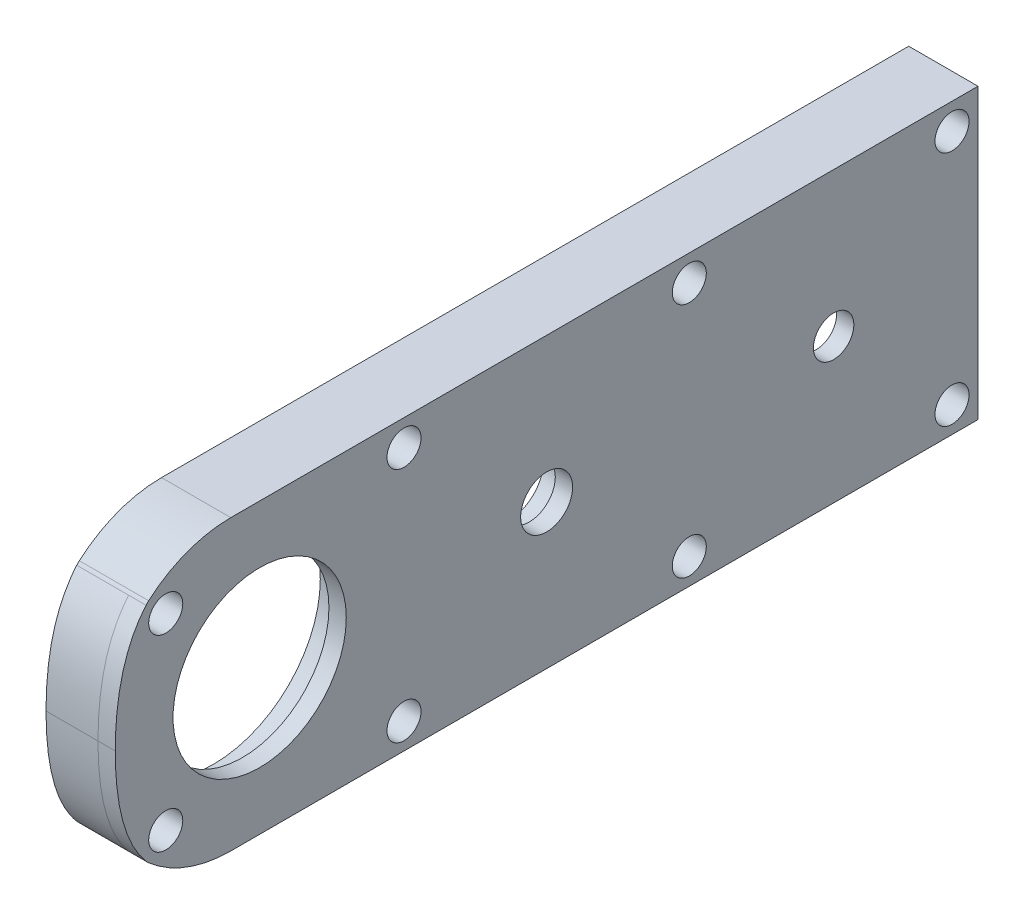
from build123d import *

# Parameters (mm, degrees)
SKETCH1_R           = 23
SKETCH1_R_2         = 18.5
BOSS_EXTRUDE1_DEPTH = 5
SKETCH2_R           = 9.5
SKETCH2_R_2         = 6
BOSS_EXTRUDE2_DEPTH = 3.5
SKETCH3_W           = 149.4
SKETCH3_H           = 50
SKETCH3_R           = 15
SKETCH3_R_2         = 4.5
SKETCH3_R_3         = 3.5
BOSS_EXTRUDE3_DEPTH = 3
BOSS_EXTRUDE4_DEPTH = 9
CUT_EXTRUDE1_DEPTH  = 128.205974827
SKETCH6_R           = 2
CUT_EXTRUDE2_DEPTH  = 128.453364147
SKETCH7_R           = 2.95
CUT_EXTRUDE3_DEPTH  = 5


with BuildPart() as part:
    # Sketch1 → Boss-Extrude1 (new body)
    with BuildSketch(Plane(origin=(0, 0, 0), x_dir=(0, 0, -1), z_dir=(1, 0, 0))):
        Circle(SKETCH1_R)
        Circle(SKETCH1_R_2, mode=Mode.SUBTRACT)
    extrude(amount=-BOSS_EXTRUDE1_DEPTH)



with BuildPart() as body_2:
    # Sketch2 → Boss-Extrude2 (new body)
    with BuildSketch(Plane(origin=(0, 0, 0), x_dir=(0, 0, -1), z_dir=(1, 0, 0))):
        with Locations((49.7, 0)):
            Circle(SKETCH2_R)
        with Locations((49.7, 0)):
            Circle(SKETCH2_R_2, mode=Mode.SUBTRACT)
    extrude(amount=-BOSS_EXTRUDE2_DEPTH)


with BuildPart() as part_1:
    add(part.part)

    add(body_2.part)  # Boss-Extrude3 merges body 2
    # Sketch3 → Boss-Extrude3 (add)
    with BuildSketch(Plane(origin=(0, 0, 0), x_dir=(0, 0, -1), z_dir=(1, 0, 0))):
        with Locations((49.7, 0)):
            Rectangle(SKETCH3_W, SKETCH3_H)
        Circle(SKETCH3_R, mode=Mode.SUBTRACT)
        with Locations((49.7, 0)):
            Circle(SKETCH3_R_2, mode=Mode.SUBTRACT)
        with Locations((99.4, 0)):
            Circle(SKETCH3_R_3, mode=Mode.SUBTRACT)
    extrude(amount=BOSS_EXTRUDE3_DEPTH)

    # Sketch4 → Boss-Extrude4 (add)
    with BuildSketch(Plane.ZY):
        with BuildLine():
            Line((-4.769696007, 22.5), (-20.968871126, 22.5))
            ThreePointArc((-20.968871126, 22.5), (-25, 16), (-29.031128874, 22.5))
            Line((-29.031128874, 22.5), (-70.368871126, 22.5))
            ThreePointArc((-70.368871126, 22.5), (-74.4, 16), (-78.431128874, 22.5))
            Line((-78.431128874, 22.5), (-115.868871126, 22.5))
            ThreePointArc((-115.868871126, 22.5), (-116.718019485, 17.318019485), (-121.9, 16.468871126))
            Line((-121.9, 16.468871126), (-121.9, 0))
            Line((-121.9, 0), (-124.4, 0))
            Line((-124.4, 0), (-124.4, 25))
            Line((-124.4, 25), (-25, 25))
            Line((-25, 25), (5, 25))
            ThreePointArc((5, 25), (12.601163208, 23.617752147), (19.229080139, 19.647990392))
            ThreePointArc((19.229080139, 19.647990392), (19.460897577, 19.429899895), (19.676719473, 19.195968924))
            add(Edge.make_bspline(
                [(25, 0), (25, 13), (19.676719473, 19.195968924)],
                knots=[0, 0, 0, 1, 1, 1], degree=2))
            Line((25, 0), (18.5, 0))
            ThreePointArc((18.5, 0), (17.091771351, 7.079643499), (13.081475452, 13.081475452))
            ThreePointArc((13.081475452, 13.081475452), (11.76885524, 16.04308286), (12.785457038, 19.118893491))
            ThreePointArc((12.785457038, 19.118893491), (4.34983638, 22.584926909), (-4.769696007, 22.5))
        make_face()
    boss_extrude4 = extrude(amount=BOSS_EXTRUDE4_DEPTH)

    # Sketch5 → Cut-Extrude1 (cut, symmetric)
    with BuildSketch(Plane.ZY):
        with BuildLine():
            Line((25, 0), (25, 25))
            Line((25, 25), (5, 25))
            ThreePointArc((5, 25), (12.601163208, 23.617752147), (19.229080139, 19.647990392))
            ThreePointArc((19.229080139, 19.647990392), (19.460897577, 19.429899895), (19.676719473, 19.195968924))
            add(Edge.make_bspline(
                [(19.676719473, 19.195968924), (25, 13), (25, 0)],
                knots=[0, 0, 0, 1, 1, 1], degree=2))
        make_face()
    cut_extrude1 = extrude(amount=CUT_EXTRUDE1_DEPTH, both=True, mode=Mode.SUBTRACT)

    # Sketch6 → Cut-Extrude2 (cut, through all)
    with BuildSketch(Plane.ZY.offset(9)):
        with Locations((16.263455967, 16.263455967)):
            Circle(SKETCH6_R)
        with Locations((-25, 20.5)):
            Circle(SKETCH6_R)
        with Locations((-74.4, 20.5)):
            Circle(SKETCH6_R)
        with Locations((-119.9, 20.5)):
            Circle(SKETCH6_R)
    cut_extrude2 = extrude(amount=-CUT_EXTRUDE2_DEPTH, mode=Mode.SUBTRACT)

    # Sketch7 → Cut-Extrude3 (cut)
    with BuildSketch(Plane(origin=(3, 0, 0), x_dir=(0, 0, -1), z_dir=(1, 0, 0))):
        with Locations((-16.263455967, 16.263455967)):
            Circle(SKETCH7_R)
        with Locations((25, 20.5)):
            Circle(SKETCH7_R)
        with Locations((74.4, 20.5)):
            Circle(SKETCH7_R)
        with Locations((119.9, 20.5)):
            Circle(SKETCH7_R)
    cut_extrude3 = extrude(amount=-CUT_EXTRUDE3_DEPTH, mode=Mode.SUBTRACT)

    # Mirror1: Boss-Extrude4, Cut-Extrude1, Cut-Extrude2, Cut-Extrude3 across plane
    add(boss_extrude4.mirror(Plane.ZX))
    add(cut_extrude1.mirror(Plane.ZX), mode=Mode.SUBTRACT)
    add(cut_extrude2.mirror(Plane.ZX), mode=Mode.SUBTRACT)
    add(cut_extrude3.mirror(Plane.ZX), mode=Mode.SUBTRACT)


solid = part_1.part
